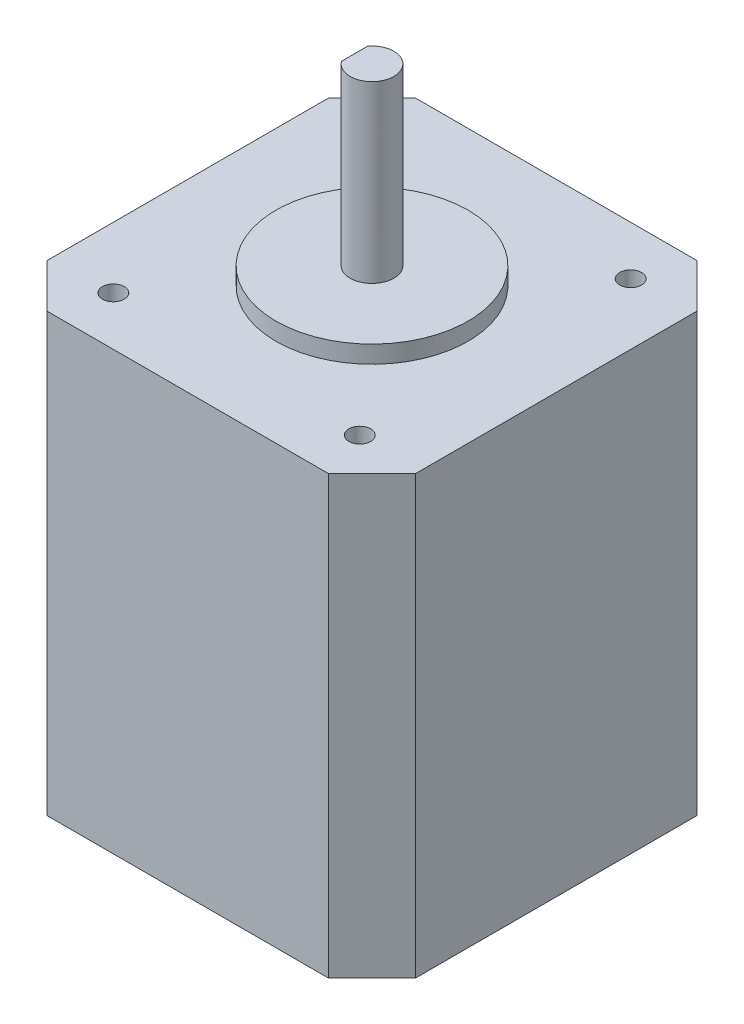
from build123d import *

# Parameters (mm, degrees)
SKETCH_1_R      = 1.25
SKETCH_1_R_2    = 11
EXTRUDE_1_DEPTH = 50
SKETCH_1_3_R    = 11
EXTRUDE_2_DEPTH = 52
EXTRUDE_3_DEPTH = 72
EXTRUDE_4_DEPTH = 57
SKETCH_2_W      = 20
SKETCH_2_H      = 9
EXTRUDE_5_DEPTH = 6


with BuildPart() as part:
    # 草图1 → 凸台-拉伸1 (new body)
    with BuildSketch(Plane(origin=(0, 0, 0), x_dir=(1, 0, 0), z_dir=(0, 1, 0))):
        Polygon((-21.1, -16.1), (-16.1, -21.1), (16.1, -21.1), (21.1, -16.1), (21.1, 16.1), (16.1, 21.1), (-16.1, 21.1), (-21.1, 16.1), align=None)
        with Locations((-14.1, -15.5)):
            Circle(SKETCH_1_R, mode=Mode.SUBTRACT)
        with Locations((14.1, -15.5)):
            Circle(SKETCH_1_R, mode=Mode.SUBTRACT)
        with Locations((-14.1, 15.5)):
            Circle(SKETCH_1_R, mode=Mode.SUBTRACT)
        Circle(SKETCH_1_R_2, mode=Mode.SUBTRACT)
        with Locations((14.1, 15.5)):
            Circle(SKETCH_1_R, mode=Mode.SUBTRACT)
    extrude(amount=EXTRUDE_1_DEPTH)

    # 草图1<3> → 凸台-拉伸2 (add)
    with BuildSketch(Plane(origin=(0, 0, 0), x_dir=(1, 0, 0), z_dir=(0, 1, 0))):
        Circle(SKETCH_1_3_R)
        with BuildLine():
            ThreePointArc((-2, -1.5), (-2.5, 0), (-2, 1.5))
            ThreePointArc((-2, 1.5), (0.790569415, 2.371708245), (2.5, 0))
            ThreePointArc((2.5, 0), (0.790569415, -2.371708245), (-2, -1.5))
        make_face(mode=Mode.SUBTRACT)
    extrude(amount=EXTRUDE_2_DEPTH)

    # 草图1<4> → 凸台-拉伸3 (add)
    with BuildSketch(Plane(origin=(0, 0, 0), x_dir=(1, 0, 0), z_dir=(0, 1, 0))):
        with BuildLine():
            ThreePointArc((2.5, 0), (0.790569415, 2.371708245), (-2, 1.5))
            Line((-2, 1.5), (-2, -1.5))
            ThreePointArc((-2, -1.5), (0.790569415, -2.371708245), (2.5, 0))
        make_face()
    extrude(amount=EXTRUDE_3_DEPTH)

    # 草图1<5> → 凸台-拉伸4 (add)
    with BuildSketch(Plane(origin=(0, 0, 0), x_dir=(1, 0, 0), z_dir=(0, 1, 0))):
        with BuildLine():
            Line((-2, -1.5), (-2, 1.5))
            ThreePointArc((-2, 1.5), (-2.5, 0), (-2, -1.5))
        make_face()
    extrude(amount=EXTRUDE_4_DEPTH)

    # 草图2 → 凸台-拉伸5 (add)
    with BuildSketch(Plane(origin=(0, 0, -21.1), x_dir=(-1, 0, 0), z_dir=(0, 0, -1))):
        with Locations((0, 4.5)):
            Rectangle(SKETCH_2_W, SKETCH_2_H)
    extrude(amount=EXTRUDE_5_DEPTH)


solid = part.part
